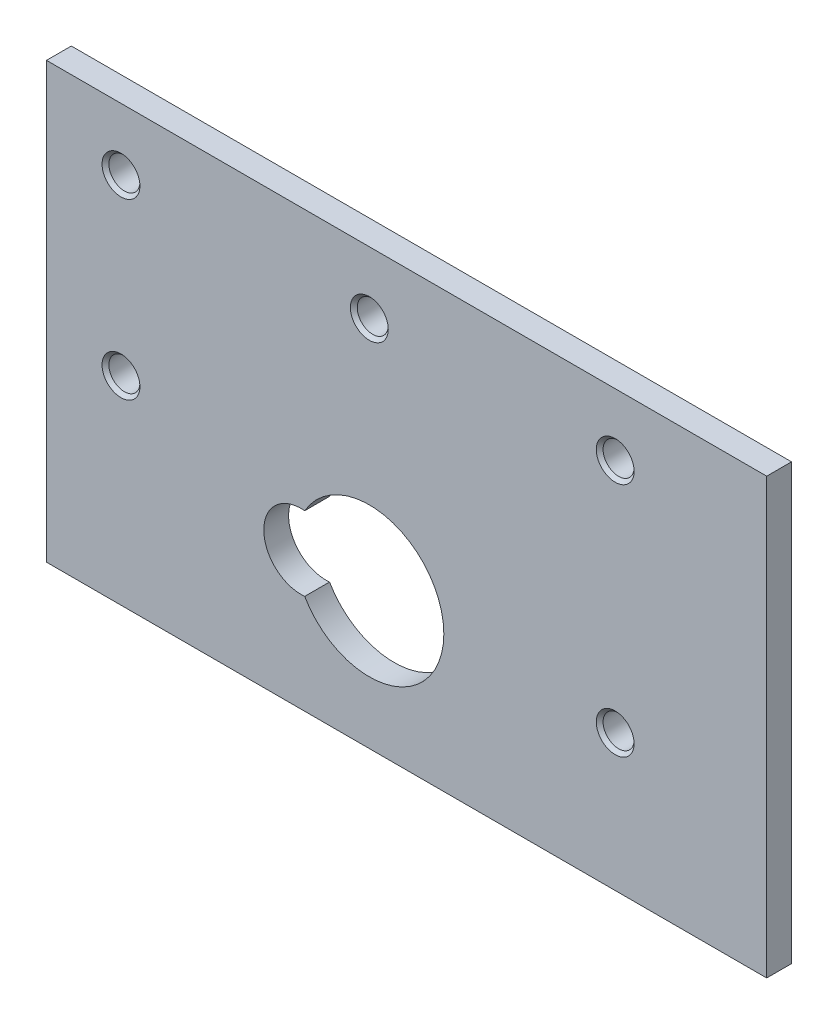
from build123d import *

# Parameters (mm, degrees)
SKETCH1_W                       = 58
SKETCH1_H                       = 35
BOSS_EXTRUDE2_DEPTH             = 2
M3X0_5_TAPPED_HOLE3_D           = 2.5
M3X0_5_TAPPED_HOLE3_CSINK_D     = 3.05
M3X0_5_TAPPED_HOLE3_CSINK_ANGLE = 90
CUT_EXTRUDE1_DEPTH              = 3


with BuildPart() as part:
    # Sketch1 → Boss-Extrude2 (new body)
    with BuildSketch(Plane.XY):
        Rectangle(SKETCH1_W, SKETCH1_H)
    extrude(amount=BOSS_EXTRUDE2_DEPTH)

    # M3x0.5 Tapped Hole3 (through all)
    with Locations(Plane.XY.offset(2)):
        with Locations((-23, 12.5), (-3, 12.5), (16.8, 12.5), (16.8, -6.5), (-23, -1.5)):
            CounterSinkHole(M3X0_5_TAPPED_HOLE3_D / 2, M3X0_5_TAPPED_HOLE3_CSINK_D / 2, counter_sink_angle=M3X0_5_TAPPED_HOLE3_CSINK_ANGLE)

    # Sketch11 → Cut-Extrude1 (cut, through all)
    with BuildSketch(Plane.XY.offset(2)):
        with BuildLine():
            ThreePointArc((-8.204545455, -3.514584349), (-11.5, -6.5), (-8.204545455, -9.485415651))
            ThreePointArc((-8.204545455, -9.485415651), (3, -6.5), (-8.204545455, -3.514584349))
        make_face()
    extrude(amount=-CUT_EXTRUDE1_DEPTH, mode=Mode.SUBTRACT)


solid = part.part
